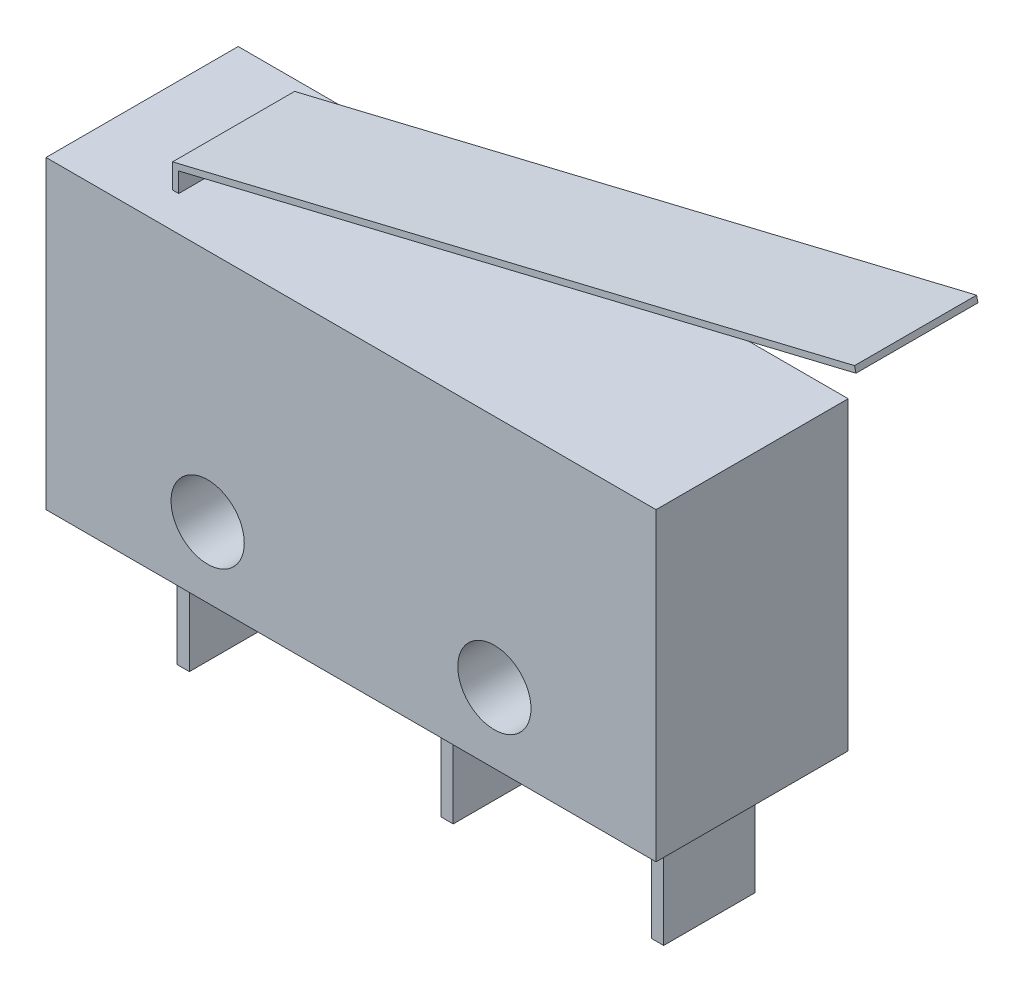
from build123d import *

# Parameters (mm, degrees)
ESBO_O1_R                = 1.2
RESSALTO_EXTRUS_O1_DEPTH = 6.3
ESBO_O2_W                = 1.65
ESBO_O2_H                = 3.9
CORTE_EXTRUS_O1_DEPTH    = 21
ESBO_O3_W                = 1.15
ESBO_O3_H                = 6.194421291
CORTE_EXTRUS_O2_DEPTH    = 23.405356502


with BuildPart() as part:
    # Esboço1 → Ressalto-extrusão1 (new body)
    with BuildSketch(Plane.XY):
        Polygon((1.7, -5), (8.2, -5), (8.2, -8.9), (8.6, -8.9), (8.6, -5), (10, -5), (10, 5), (-6.8, 5), (-6.8, 5.642515202), (15.405356502, 11), (15.358448491, 11.194421291), (-7, 5.8), (-7, 5), (-10, 5), (-10, -5), (-7.35, -5), (-7.35, -8.9), (-6.95, -8.9), (-6.95, -5), (1.3, -5), (1.3, -8.9), (1.7, -8.9), align=None)
        with Locations((-4.7, -2.7)):
            Circle(ESBO_O1_R, mode=Mode.SUBTRACT)
        with Locations((4.7, -2.7)):
            Circle(ESBO_O1_R, mode=Mode.SUBTRACT)
    extrude(amount=RESSALTO_EXTRUS_O1_DEPTH)

    # Esboço2 → Corte-extrusão1 (cut, through all)
    with BuildSketch(Plane(origin=(10, 0, 0), x_dir=(0, 0, -1), z_dir=(1, 0, 0))):
        with Locations((-0.825, -6.95)):
            Rectangle(ESBO_O2_W, ESBO_O2_H)
        with Locations((-5.475, -6.95)):
            Rectangle(ESBO_O2_W, ESBO_O2_H)
    extrude(amount=-CORTE_EXTRUS_O1_DEPTH, mode=Mode.SUBTRACT)

    # Esboço3 → Corte-extrusão2 (cut, through all)
    with BuildSketch(Plane.ZY.offset(7)):
        with Locations((0.575, 8.097210646)):
            Rectangle(ESBO_O3_W, ESBO_O3_H)
        with Locations((5.725, 8.097210646)):
            Rectangle(ESBO_O3_W, ESBO_O3_H)
    extrude(amount=-CORTE_EXTRUS_O2_DEPTH, mode=Mode.SUBTRACT)


solid = part.part
